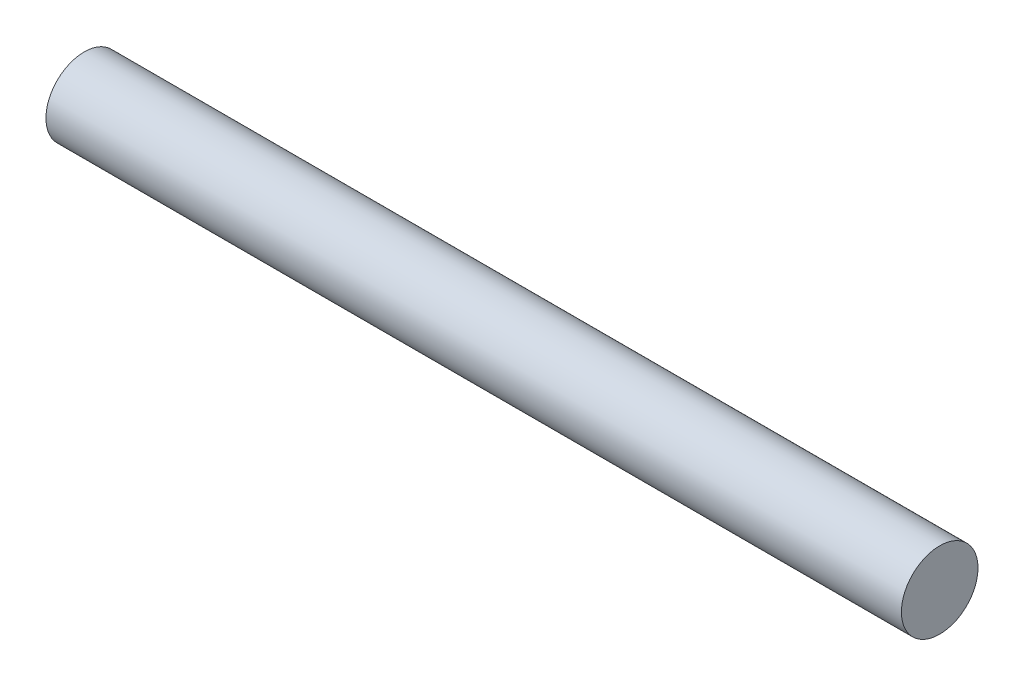
from build123d import *

# Parameters (mm, degrees)
SKETCH1_R           = 9.525
BOSS_EXTRUDE1_DEPTH = 106.3625


with BuildPart() as part:
    # Sketch1 → Boss-Extrude1 (new body, symmetric)
    with BuildSketch(Plane(origin=(0, 0, 0), x_dir=(0, 0, -1), z_dir=(1, 0, 0))):
        Circle(SKETCH1_R)
    extrude(amount=BOSS_EXTRUDE1_DEPTH, both=True)


solid = part.part
